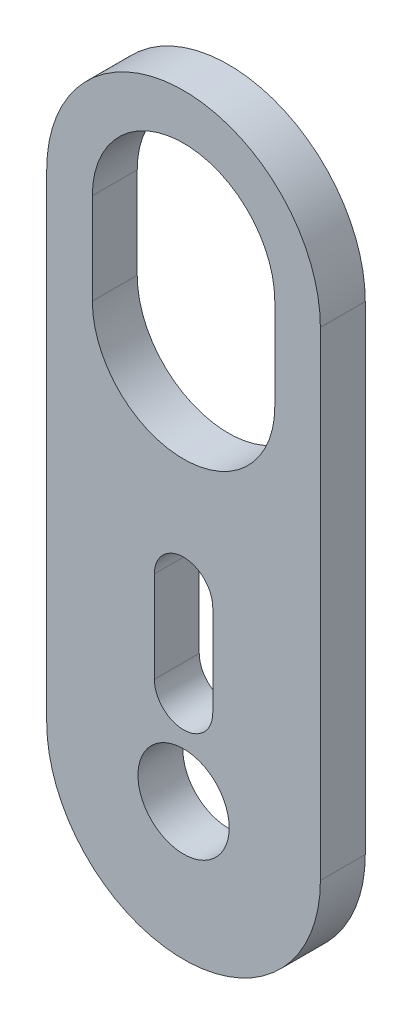
from build123d import *

# Parameters (mm, degrees)
CROQUIS1_R              = 3.175
SALIENTE_EXTRUIR1_DEPTH = 3.1242


with BuildPart() as part:
    # Croquis1 → Saliente-Extruir1 (new body)
    with BuildSketch(Plane.XY):
        with BuildLine():
            Line((-9.525, 0), (-9.525, 33.3375))
            ThreePointArc((-9.525, 33.3375), (0, 42.8625), (9.525, 33.3375))
            Line((9.525, 33.3375), (9.525, 0))
            ThreePointArc((9.525, 0), (0, -9.525), (-9.525, 0))
        make_face()
        Circle(CROQUIS1_R, mode=Mode.SUBTRACT)
        with BuildLine():
            Line((-2.032, 6.35), (-2.032, 12.7))
            ThreePointArc((-2.032, 12.7), (0, 14.732), (2.032, 12.7))
            Line((2.032, 12.7), (2.032, 6.35))
            ThreePointArc((2.032, 6.35), (0, 4.318), (-2.032, 6.35))
        make_face(mode=Mode.SUBTRACT)
        with BuildLine():
            Line((6.35, 33.3375), (6.35, 26.9875))
            ThreePointArc((6.35, 26.9875), (0, 20.6375), (-6.35, 26.9875))
            Line((-6.35, 26.9875), (-6.35, 33.3375))
            ThreePointArc((-6.35, 33.3375), (0, 39.6875), (6.35, 33.3375))
        make_face(mode=Mode.SUBTRACT)
    extrude(amount=SALIENTE_EXTRUIR1_DEPTH)


solid = part.part
